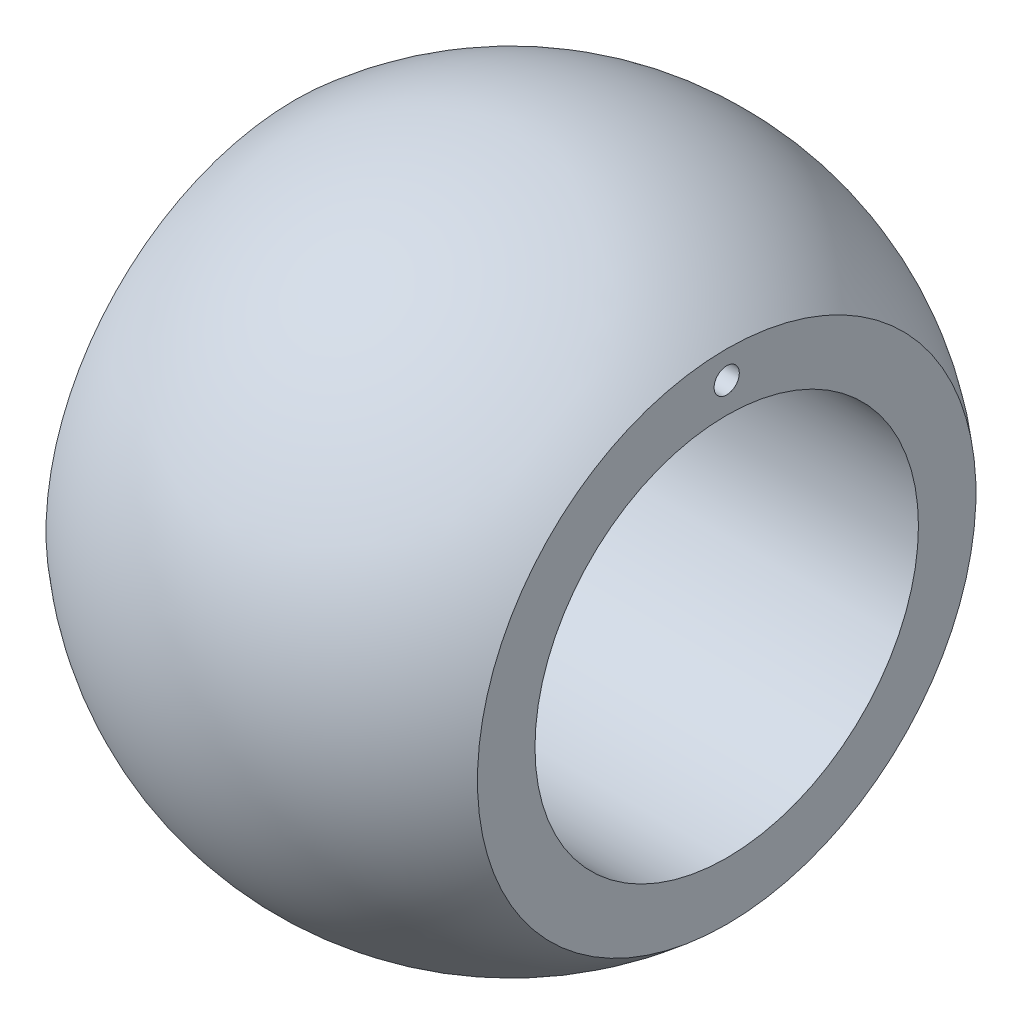
from build123d import *

# Parameters (mm, degrees)
SKETCH2_R               = 0.262991614
CUT_EXTRUDE1_DEPTH      = 1
CUT_EXTRUDE1_DEPTH_BACK = 10


with BuildPart() as part:
    # Sketch1 → Revolve1 (revolve)
    with BuildSketch(Plane.XY):
        with BuildLine():
            Line((-4.5, 4), (-4.5, 5.2))
            ThreePointArc((-4.5, 5.2), (0, 6.876772499), (4.5, 5.2))
            Line((4.5, 5.2), (4.5, 4))
            Line((4.5, 4), (-4.5, 4))
        make_face()
    revolve(axis=Axis((-6.876772499, 0, 0), (1, 0, 0)))

    # Sketch2 → Cut-Extrude1 (cut, two sides)
    with BuildSketch(Plane(origin=(4.5, 0, 0), x_dir=(0, 0, -1), z_dir=(1, 0, 0))) as cut_extrude1_sk:
        with Locations((0, 4.63)):
            Circle(SKETCH2_R)
    extrude(amount=CUT_EXTRUDE1_DEPTH, mode=Mode.SUBTRACT)
    extrude(cut_extrude1_sk.sketch, amount=-CUT_EXTRUDE1_DEPTH_BACK, mode=Mode.SUBTRACT)


solid = part.part
